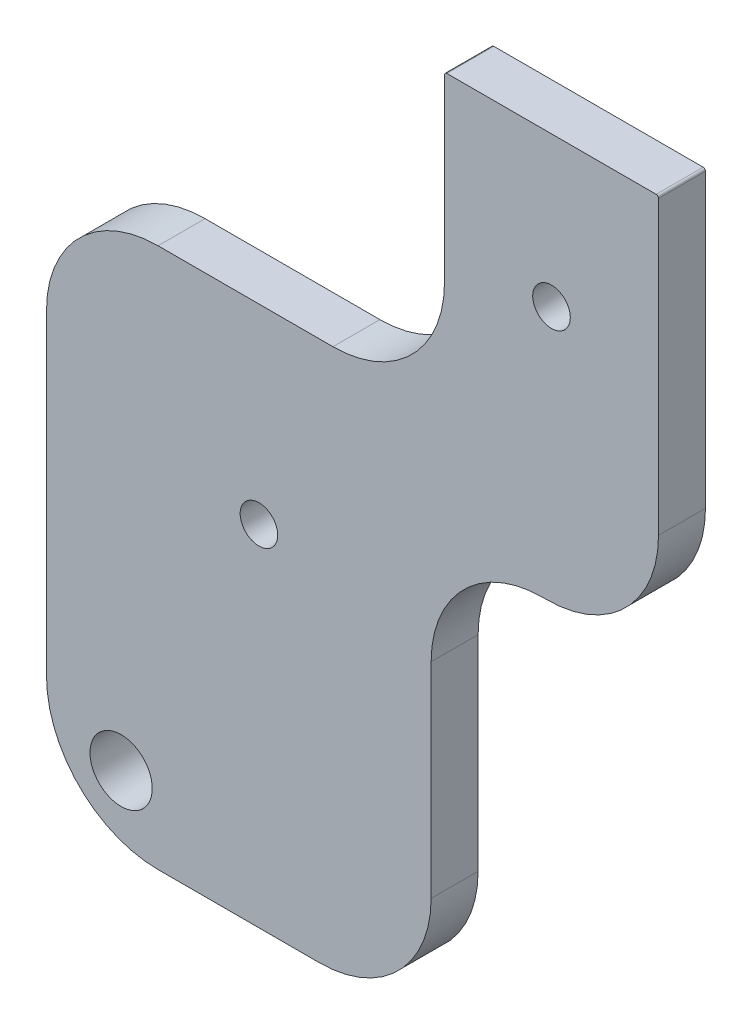
from build123d import *

# Parameters (mm, degrees)
BOSS_EXTRUDE1_DEPTH  = 4
FILLET1_R            = 9.5
M3_CLEARANCE_HOLE1_D = 3.2
M5_CLEARANCE_HOLE1_D = 5.3
FILLET2_R            = 0.2


with BuildPart() as part:
    # Sketch1 → Boss-Extrude1 (new body)
    with BuildSketch(Plane.XY):
        Polygon((73.262039089, -348.953453607), (106.008421642, -348.953453607), (106.008421642, -312.503453607), (125.368421642, -312.503453607), (125.368421642, -277.953453607), (107.148421642, -277.953453607), (107.148421642, -302.953453607), (73.262039089, -302.953453607), align=None)
    extrude(amount=-BOSS_EXTRUDE1_DEPTH)

    # Fillet1
    fillet1_edges = [part.edges().sort_by_distance(p)[0] for p in [
        (73.262039089, -302.953453607, -2),
        (107.148421642, -302.953453607, -2),
        (125.368421642, -312.503453607, -2),
        (106.008421642, -312.503453607, -2),
        (106.008421642, -348.953453607, -2),
        (73.262039089, -348.953453607, -2),
    ]]
    fillet(fillet1_edges, radius=FILLET1_R)

    # M3 Clearance Hole1 (through all)
    with Locations(Plane.XY):
        with Locations((116.258421642, -290.703453607), (91.348421642, -319.203453607)):
            Hole(M3_CLEARANCE_HOLE1_D / 2)

    # M5 Clearance Hole1 (through all)
    with Locations(Plane.XY):
        with Locations((79.612142542, -343.223274497)):
            Hole(M5_CLEARANCE_HOLE1_D / 2)

    # Fillet2
    fillet2_edges = [part.edges().sort_by_distance(p)[0] for p in [
        (107.148421642, -277.953453607, -2),
        (125.368421642, -277.953453607, -2),
    ]]
    fillet(fillet2_edges, radius=FILLET2_R)


solid = part.part
